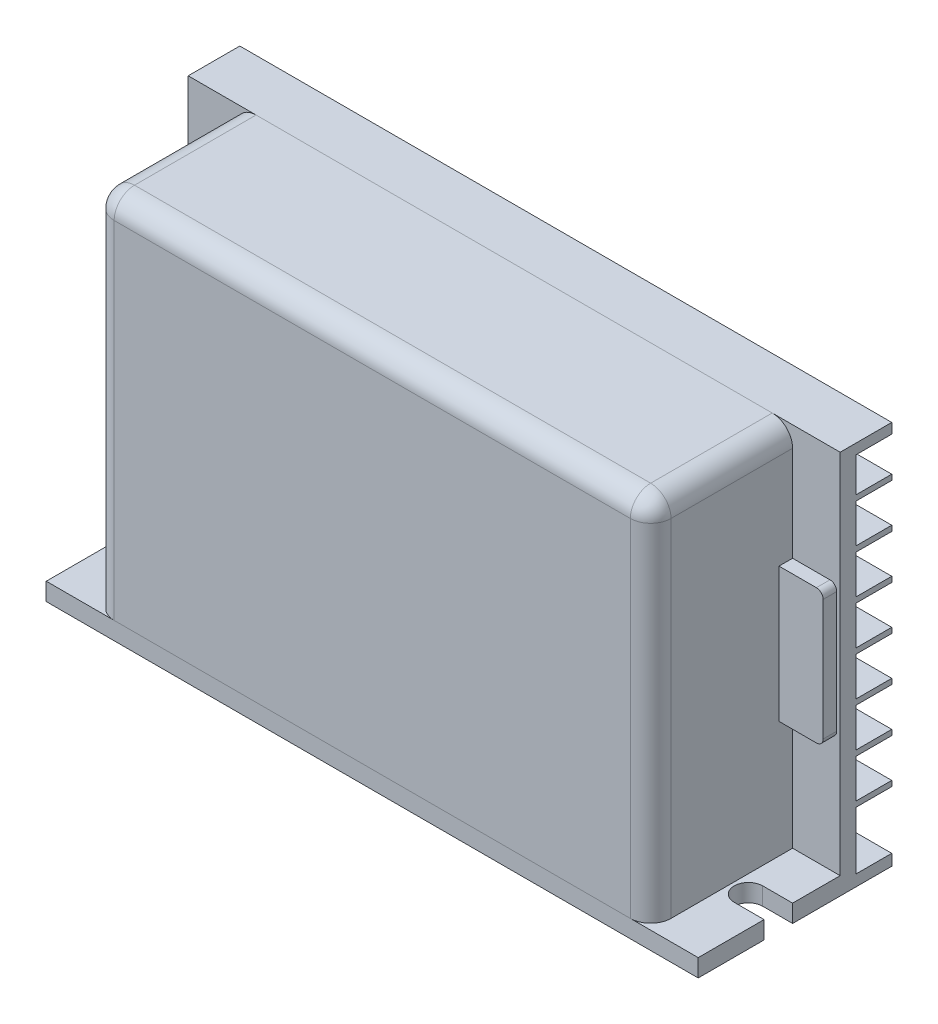
from build123d import *

# Parameters (mm, degrees)
RESSALTO_EXTRUS_O1_DEPTH   = 2.6
ESBO_O2_W                  = 96
ESBO_O2_H                  = 2.3
RESSALTO_EXTRUS_O2_DEPTH   = 54
ESBO_O3_W                  = 96
ESBO_O3_H                  = 5.3
CORTE_EXTRUS_O1_DEPTH      = 0.95
ESBO_O4_W                  = 96
ESBO_O4_H                  = 1.5
RESSALTO_EXTRUS_O3_DEPTH   = 5.3
ESBO_O5_W                  = 96
ESBO_O5_H                  = 0.8
EXTRUS_O_FINA1_DEPTH       = 5.3
RESSALTO_EXTRUS_O4_DEPTH   = 20.9
FILETE1_R                  = 3
ESBO_O7_W                  = 9.7
ESBO_O7_H                  = 18.7
CORTE_EXTRUS_O2_DEPTH      = 10
RESSALTO_EXTRUS_O5_DEPTH   = 2
RESSALTO_EXTRUS_O5_2_DEPTH = 2


with BuildPart() as part:
    # Esboço1 → Ressalto-extrusão1 (new body)
    with BuildSketch(Plane(origin=(0, 0, 0), x_dir=(1, 0, 0), z_dir=(0, 1, 0))):
        with BuildLine():
            Line((-48, -0.35), (-43.6, -0.35))
            ThreePointArc((-43.6, -0.35), (-41.5, -2.45), (-43.6, -4.55))
            Line((-43.6, -4.55), (-48, -4.55))
            Line((-48, -4.55), (-48, -14.25))
            Line((-48, -14.25), (48, -14.25))
            Line((48, -14.25), (48, -4.55))
            Line((48, -4.55), (43.6, -4.55))
            ThreePointArc((43.6, -4.55), (41.5, -2.45), (43.6, -0.35))
            Line((43.6, -0.35), (48, -0.35))
            Line((48, -0.35), (48, 14.25))
            Line((48, 14.25), (-48, 14.25))
            Line((-48, 14.25), (-48, -0.35))
        make_face()
    extrude(amount=RESSALTO_EXTRUS_O1_DEPTH)

    # Esboço2 → Ressalto-extrusão2 (add)
    with BuildSketch(Plane(origin=(0, 2.6, 0), x_dir=(1, 0, 0), z_dir=(0, 1, 0))):
        with Locations((0, 7.8)):
            Rectangle(ESBO_O2_W, ESBO_O2_H)
    extrude(amount=RESSALTO_EXTRUS_O2_DEPTH)

    # Esboço3 → Corte-extrusão1 (cut)
    with BuildSketch(Plane(origin=(0, 2.6, 0), x_dir=(1, 0, 0), z_dir=(0, 1, 0))):
        with Locations((0, 11.6)):
            Rectangle(ESBO_O3_W, ESBO_O3_H)
    extrude(amount=-CORTE_EXTRUS_O1_DEPTH, mode=Mode.SUBTRACT)

    # Esboço4 → Ressalto-extrusão3 (add)
    with BuildSketch(Plane(origin=(0, 0, -8.95), x_dir=(-1, 0, 0), z_dir=(0, 0, -1))):
        with Locations((0, 55.85)):
            Rectangle(ESBO_O4_W, ESBO_O4_H)
    extrude(amount=RESSALTO_EXTRUS_O3_DEPTH)

    # Esboço5 → Extrusão-Fina1 (add)
    with BuildSketch(Plane(origin=(0, 0, -8.95), x_dir=(-1, 0, 0), z_dir=(0, 0, -1))):
        with Locations((0, 49.6)):
            Rectangle(ESBO_O5_W, ESBO_O5_H)
        with Locations((0, 43.091666667)):
            Rectangle(ESBO_O5_W, ESBO_O5_H)
        with Locations((0, 36.583333333)):
            Rectangle(ESBO_O5_W, ESBO_O5_H)
        with Locations((0, 30.075)):
            Rectangle(ESBO_O5_W, ESBO_O5_H)
        with Locations((0, 23.566666667)):
            Rectangle(ESBO_O5_W, ESBO_O5_H)
        with Locations((0, 17.058333333)):
            Rectangle(ESBO_O5_W, ESBO_O5_H)
        with Locations((0, 10.55)):
            Rectangle(ESBO_O5_W, ESBO_O5_H)
    extrude(amount=EXTRUS_O_FINA1_DEPTH)


with BuildPart() as body_2:
    # Esboço6 → Ressalto-extrusão4 (new body)
    with BuildSketch(Plane.XY.offset(-6.65)):
        with BuildLine():
            Line((-38, 56.6), (38, 56.6))
            ThreePointArc((38, 56.6), (40.121320344, 55.721320344), (41, 53.6))
            Line((41, 53.6), (41, 2.6))
            Line((41, 2.6), (-41, 2.6))
            Line((-41, 2.6), (-41, 53.6))
            ThreePointArc((-41, 53.6), (-40.121320344, 55.721320344), (-38, 56.6))
        make_face()
    extrude(amount=RESSALTO_EXTRUS_O4_DEPTH)

    # Filete1
    filete1_edges = [body_2.edges().sort_by_distance(p)[0] for p in [
        (41, 28.1, 14.25),
        (40.121320344, 55.721320344, 14.25),
        (0, 56.6, 14.25),
        (-40.121320344, 55.721320344, 14.25),
        (-41, 28.1, 14.25),
    ]]
    fillet(filete1_edges, radius=FILETE1_R)

    # Esboço7 → Corte-extrusão2 (cut)
    with BuildSketch(Plane.ZY.offset(41)):
        with Locations((6, 31.15)):
            Rectangle(ESBO_O7_W, ESBO_O7_H)
    extrude(amount=-CORTE_EXTRUS_O2_DEPTH, mode=Mode.SUBTRACT)


with BuildPart() as body_3:
    # Esboço8 → Ressalto-extrusão5 (new body)
    with BuildSketch(Plane.XY.offset(-6.65)):
        with BuildLine():
            Line((-46.5, 39.575), (-41, 39.575))
            Line((-41, 39.575), (-41, 19.775))
            Line((-41, 19.775), (-46.5, 19.775))
            ThreePointArc((-46.5, 19.775), (-47.207106781, 20.067893219), (-47.5, 20.775))
            Line((-47.5, 20.775), (-47.5, 38.575))
            ThreePointArc((-47.5, 38.575), (-47.207106781, 39.282106781), (-46.5, 39.575))
        make_face()
    extrude(amount=RESSALTO_EXTRUS_O5_DEPTH)


with BuildPart() as body_4:
    # Esboço8 → Ressalto-extrus_o5 2 (new body)
    with BuildSketch(Plane.XY.offset(-6.65)):
        with BuildLine():
            Line((46.5, 19.775), (41, 19.775))
            Line((41, 19.775), (41, 39.575))
            Line((41, 39.575), (46.5, 39.575))
            ThreePointArc((46.5, 39.575), (47.207106781, 39.282106781), (47.5, 38.575))
            Line((47.5, 38.575), (47.5, 20.775))
            ThreePointArc((47.5, 20.775), (47.207106781, 20.067893219), (46.5, 19.775))
        make_face()
    extrude(amount=RESSALTO_EXTRUS_O5_2_DEPTH)


solid = Compound([part.part, body_2.part, body_3.part, body_4.part])
